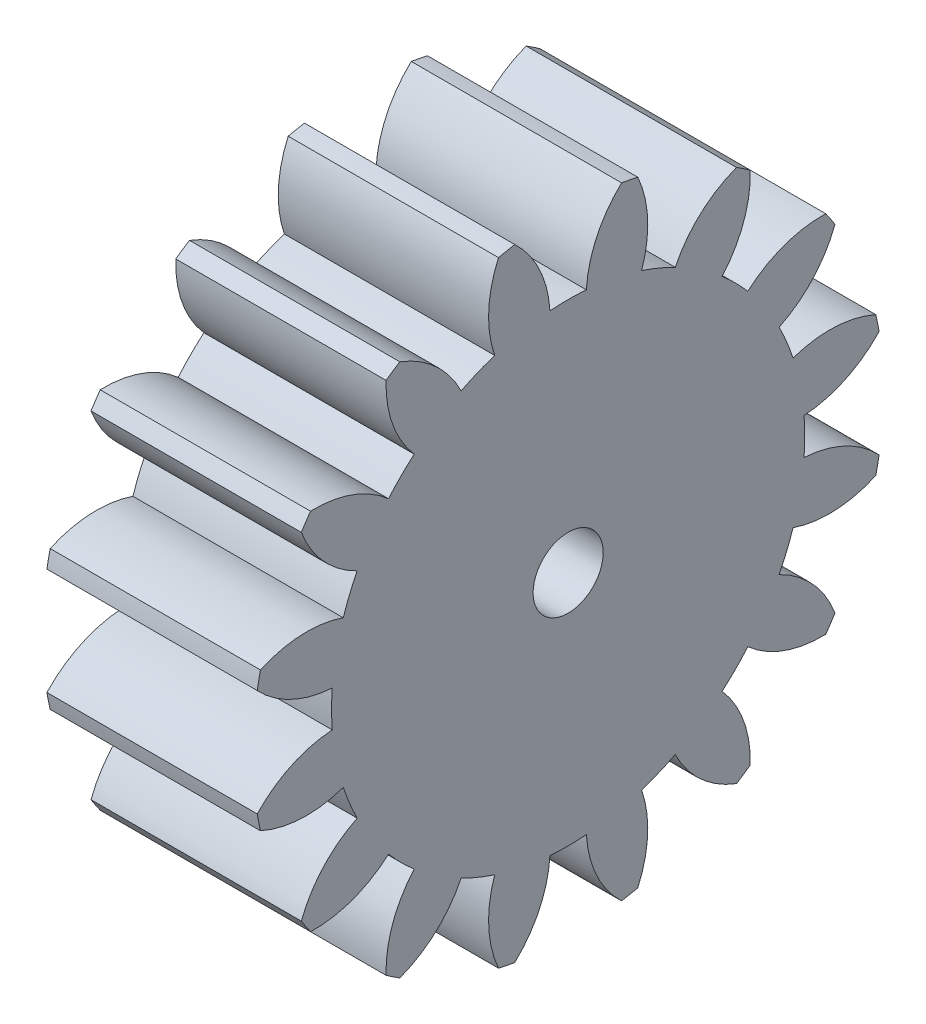
from build123d import *

# Parameters (mm, degrees)
BASPROSKE_W     = 15
BASPROSKE_H     = 22.5
TOOTHCUT_DEPTH  = 36.178118199
TEETHCUTS_COUNT = 16
TEETHCUTS_ANGLE = 337.5
BORSKE_R        = 2.5
BORE_DEPTH      = 50.0000508


with BuildPart() as part:
    # BasProSke → Base-Revolve (revolve)
    with BuildSketch(Plane(origin=(0, 0, 0), x_dir=(1, 0, 0), z_dir=(0, 1, 0)), mode=Mode.PRIVATE) as base_revolve_sk:
        with Locations((7.5, 11.25)):
            Rectangle(BASPROSKE_W, BASPROSKE_H)
    revolve(base_revolve_sk.sketch.rotate(Axis((-10, 0, 0), (1, 0, 0)), 180), axis=Axis((-10, 0, 0), (1, 0, 0)))

    # TooCutSke → ToothCut (cut, through all)
    with BuildSketch(Plane(origin=(0, 0, 0), x_dir=(0, 0, -1), z_dir=(1, 0, 0))):
        with BuildLine():
            ThreePointArc((1.297749273, 16.824022195), (0, 16.874), (-1.297749273, 16.824022195))
            ThreePointArc((-1.297749273, 16.824022195), (-2.047921493, 19.754510488), (-3.832565589, 22.196961192))
            ThreePointArc((-3.832565589, 22.196961192), (0, 22.5254), (3.832565589, 22.196961192))
            ThreePointArc((3.832565589, 22.196961192), (2.047921493, 19.754510488), (1.297749273, 16.824022195))
        make_face()
    toothcut = extrude(amount=TOOTHCUT_DEPTH, mode=Mode.SUBTRACT)

    # TeethCuts: ToothCut ×16 about axis
    teethcuts_axis = Axis((-10, 0, 0), (1, 0, 0))
    for i in range(1, TEETHCUTS_COUNT):
        add(toothcut.rotate(teethcuts_axis, i * TEETHCUTS_ANGLE / (TEETHCUTS_COUNT - 1)), mode=Mode.SUBTRACT)

    # BorSke → Bore (cut, symmetric)
    with BuildSketch(Plane(origin=(0, 0, 0), x_dir=(0, 0, -1), z_dir=(1, 0, 0))):
        with Locations(Location((0, 0, 0), (0, 0, 180))):
            Circle(BORSKE_R)
    extrude(amount=BORE_DEPTH, both=True, mode=Mode.SUBTRACT)


solid = part.part
